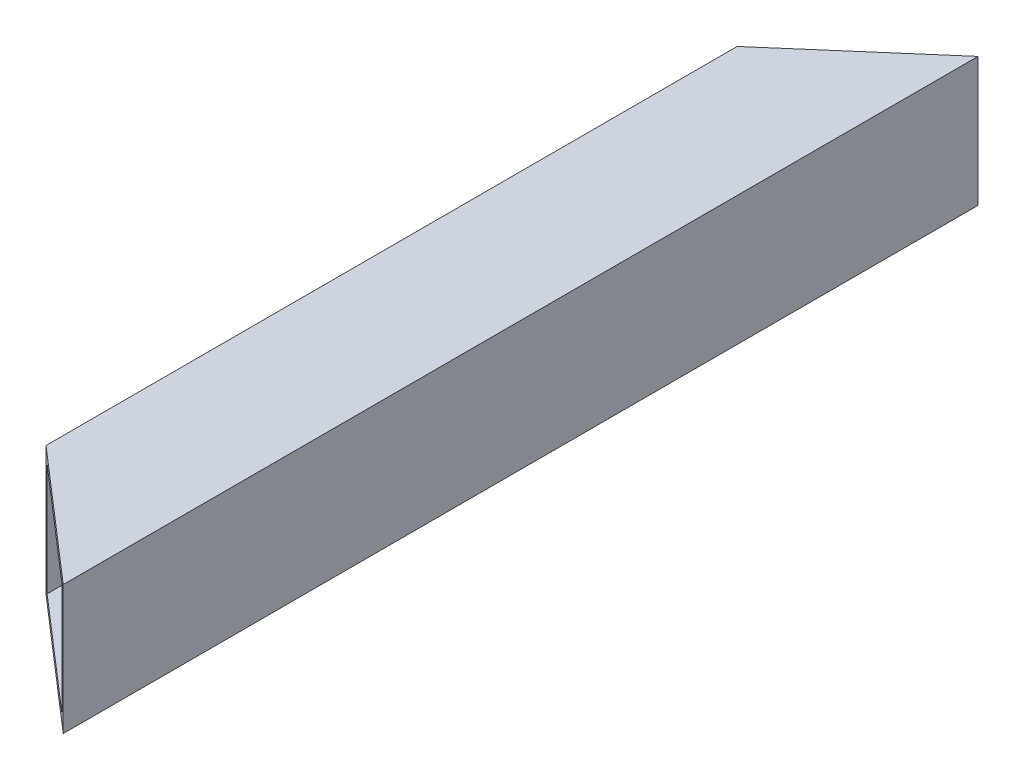
from build123d import *

# Parameters (mm, degrees)
SKETCH1_W           = 25.4
SKETCH1_H           = 25.4
SKETCH1_W_2         = 22.098
SKETCH1_H_2         = 22.098
BOSS_EXTRUDE1_DEPTH = 158.03712
SKETCH7_W           = 25.4
SKETCH7_H           = 25.4
SKETCH7_W_2         = 22.098
SKETCH7_H_2         = 22.098
BOSS_EXTRUDE2_DEPTH = 12.7
CUT_EXTRUDE1_DEPTH  = 36.4
SKETCH9_W           = 25.4
SKETCH9_H           = 25.4
SKETCH9_W_2         = 22.098
SKETCH9_H_2         = 22.098
BOSS_EXTRUDE3_DEPTH = 25.4
CUT_EXTRUDE2_DEPTH  = 36.4


with BuildPart() as part:
    # Sketch1 → Boss-Extrude1 (new body)
    with BuildSketch(Plane.XY):
        Rectangle(SKETCH1_W, SKETCH1_H)
        Rectangle(SKETCH1_W_2, SKETCH1_H_2, mode=Mode.SUBTRACT)
    extrude(amount=BOSS_EXTRUDE1_DEPTH)

    # Sketch7 → Boss-Extrude2 (add)
    with BuildSketch(Plane(origin=(0, 0, 0), x_dir=(-1, 0, 0), z_dir=(0, 0, -1))):
        Rectangle(SKETCH7_W, SKETCH7_H)
        Rectangle(SKETCH7_W_2, SKETCH7_H_2, mode=Mode.SUBTRACT)
    extrude(amount=BOSS_EXTRUDE2_DEPTH)

    # Sketch8 → Cut-Extrude1 (cut, through all)
    with BuildSketch(Plane(origin=(0, 22.7, 0), x_dir=(1, 0, 0), z_dir=(0, 1, 0))):
        Polygon((42.140856973, 36.508313653), (-34.628433436, -30), (-56.571600074, 82.773791124), align=None)
    extrude(amount=-CUT_EXTRUDE1_DEPTH, mode=Mode.SUBTRACT)

    # Sketch9 → Boss-Extrude3 (add)
    with BuildSketch(Plane.XY.offset(158.037119512)):
        Rectangle(SKETCH9_W, SKETCH9_H)
        Rectangle(SKETCH9_W_2, SKETCH9_H_2, mode=Mode.SUBTRACT)
    extrude(amount=BOSS_EXTRUDE3_DEPTH)

    # Sketch11 → Cut-Extrude2 (cut, through all)
    with BuildSketch(Plane(origin=(-388.03129279, 22.7, 553.337933672), x_dir=(-1, 0, 0), z_dir=(0, 1, 0))):
        Polygon((-356.047433406, -423.010988055), (-328.054453058, -334.045248583), (-413.969286498, -372.828656955), align=None)
    extrude(amount=-CUT_EXTRUDE2_DEPTH, mode=Mode.SUBTRACT)


solid = part.part
